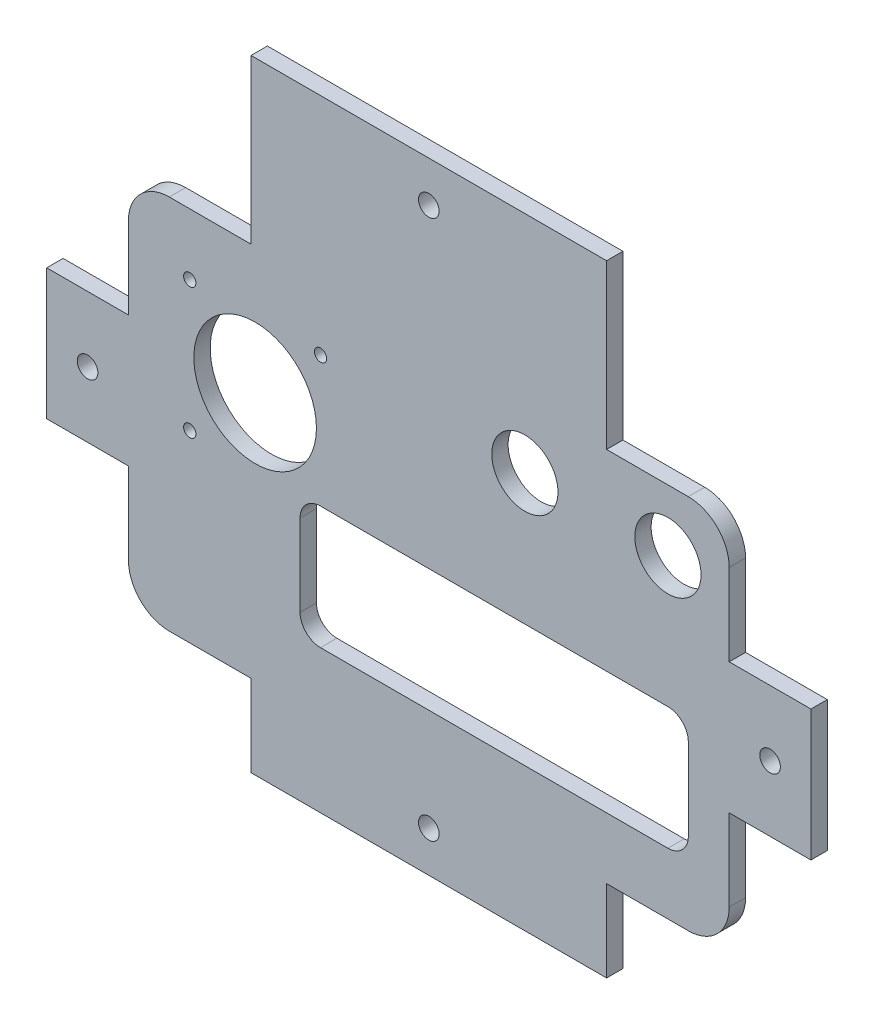
from build123d import *

# Parameters (mm, degrees)
MODEL_R             = 8.1
MODEL_R_2           = 1.5
MODEL_R_3           = 2.525
MODEL_R_4           = 15
BOSS_EXTRUDE1_DEPTH = 4


with BuildPart() as part:
    # Model → Boss-Extrude1 (new body)
    with BuildSketch(Plane.XY):
        with BuildLine():
            Line((-93.5, -16), (-73.5, -16))
            Line((-73.5, -16), (-73.5, -36))
            ThreePointArc((-73.5, -36), (-70.571067812, -43.071067812), (-63.5, -46))
            Line((-63.5, -46), (-43.5, -46))
            Line((-43.5, -46), (-43.5, -66))
            Line((-43.5, -66), (43.5, -66))
            Line((43.5, -66), (43.5, -46))
            Line((43.5, -46), (63.5, -46))
            ThreePointArc((63.5, -46), (70.571067812, -43.071067812), (73.5, -36))
            Line((73.5, -36), (73.5, -16))
            Line((73.5, -16), (93.5, -16))
            Line((93.5, -16), (93.5, 16))
            Line((93.5, 16), (73.5, 16))
            Line((73.5, 16), (73.5, 36))
            ThreePointArc((73.5, 36), (70.571067812, 43.071067812), (63.5, 46))
            Line((63.5, 46), (43.5, 46))
            Line((43.5, 46), (43.5, 86))
            Line((43.5, 86), (-43.5, 86))
            Line((-43.5, 86), (-43.5, 46))
            Line((-43.5, 46), (-63.5, 46))
            ThreePointArc((-63.5, 46), (-70.571067812, 43.071067812), (-73.5, 36))
            Line((-73.5, 36), (-73.5, 16))
            Line((-73.5, 16), (-93.5, 16))
            Line((-93.5, 16), (-93.5, -16))
        make_face()
        with Locations((23.5, 31)):
            Circle(MODEL_R, mode=Mode.SUBTRACT)
        with Locations((-26.5, 31)):
            Circle(MODEL_R_2, mode=Mode.SUBTRACT)
        with Locations((-58.5, 31)):
            Circle(MODEL_R_2, mode=Mode.SUBTRACT)
        with Locations((83.5, 0)):
            Circle(MODEL_R_3, mode=Mode.SUBTRACT)
        with Locations((0, 76)):
            Circle(MODEL_R_3, mode=Mode.SUBTRACT)
        with Locations((-83.5, 0)):
            Circle(MODEL_R_3, mode=Mode.SUBTRACT)
        with Locations((0, -56)):
            Circle(MODEL_R_3, mode=Mode.SUBTRACT)
        with Locations((-58.5, -1)):
            Circle(MODEL_R_2, mode=Mode.SUBTRACT)
        with Locations((58.5, 31)):
            Circle(MODEL_R, mode=Mode.SUBTRACT)
        with Locations((-42.5, 15)):
            Circle(MODEL_R_4, mode=Mode.SUBTRACT)
        with BuildLine():
            Line((58.5, -1), (-26.5, -1))
            ThreePointArc((-26.5, -1), (-30.035533906, -2.464466094), (-31.5, -6))
            Line((-31.5, -6), (-31.5, -26))
            ThreePointArc((-31.5, -26), (-30.035533906, -29.535533906), (-26.5, -31))
            Line((-26.5, -31), (58.5, -31))
            ThreePointArc((58.5, -31), (62.035533906, -29.535533906), (63.5, -26))
            Line((63.5, -26), (63.5, -6))
            ThreePointArc((63.5, -6), (62.035533906, -2.464466094), (58.5, -1))
        make_face(mode=Mode.SUBTRACT)
    extrude(amount=BOSS_EXTRUDE1_DEPTH)


solid = part.part
